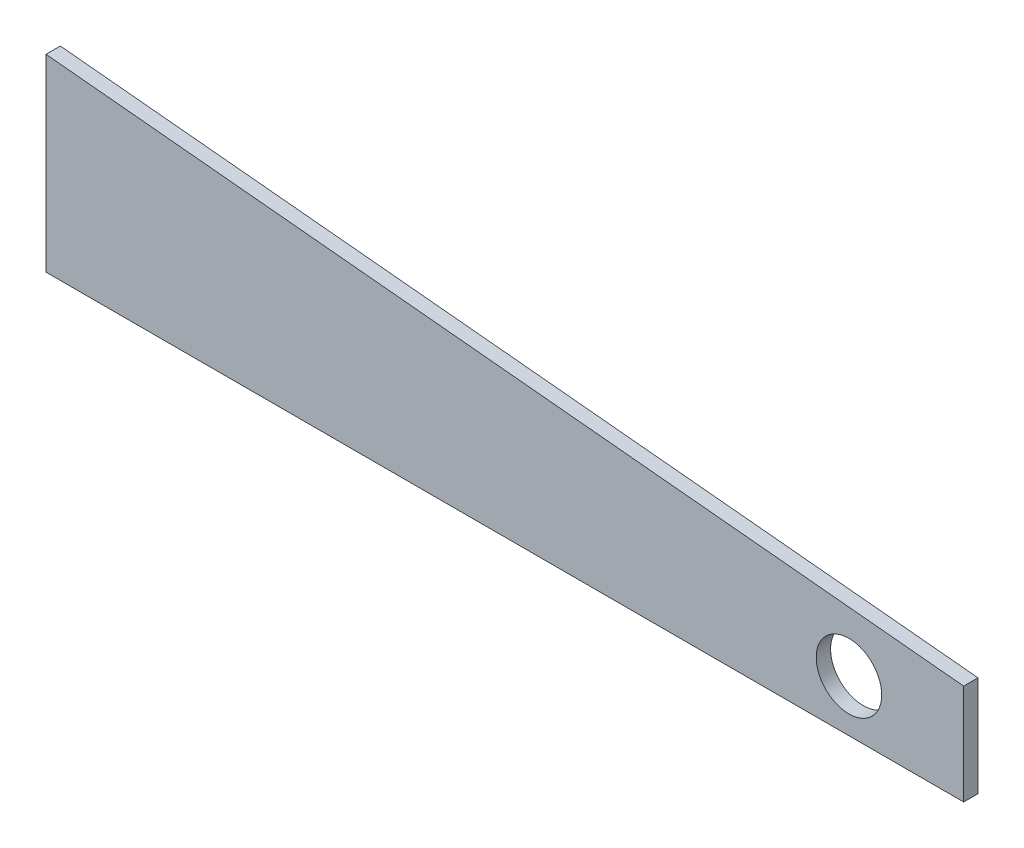
from build123d import *

# Parameters (mm, degrees)
BOSS_EXTRUDE1_DEPTH = 6.35
SKETCH2_R           = 14.499971
CUT_EXTRUDE1_DEPTH  = 6.35


with BuildPart() as part:
    # Sketch1 → Boss-Extrude1 (new body)
    with BuildSketch(Plane.XY):
        Polygon((0, 0), (406.4, 0), (406.4, 44.45), (0, 83.566), align=None)
    extrude(amount=BOSS_EXTRUDE1_DEPTH)

    # Sketch2 → Cut-Extrude1 (cut)
    with BuildSketch(Plane.XY.offset(6.35)):
        with Locations((355.6, 22.86)):
            Circle(SKETCH2_R)
    extrude(amount=-CUT_EXTRUDE1_DEPTH, mode=Mode.SUBTRACT)


solid = part.part
